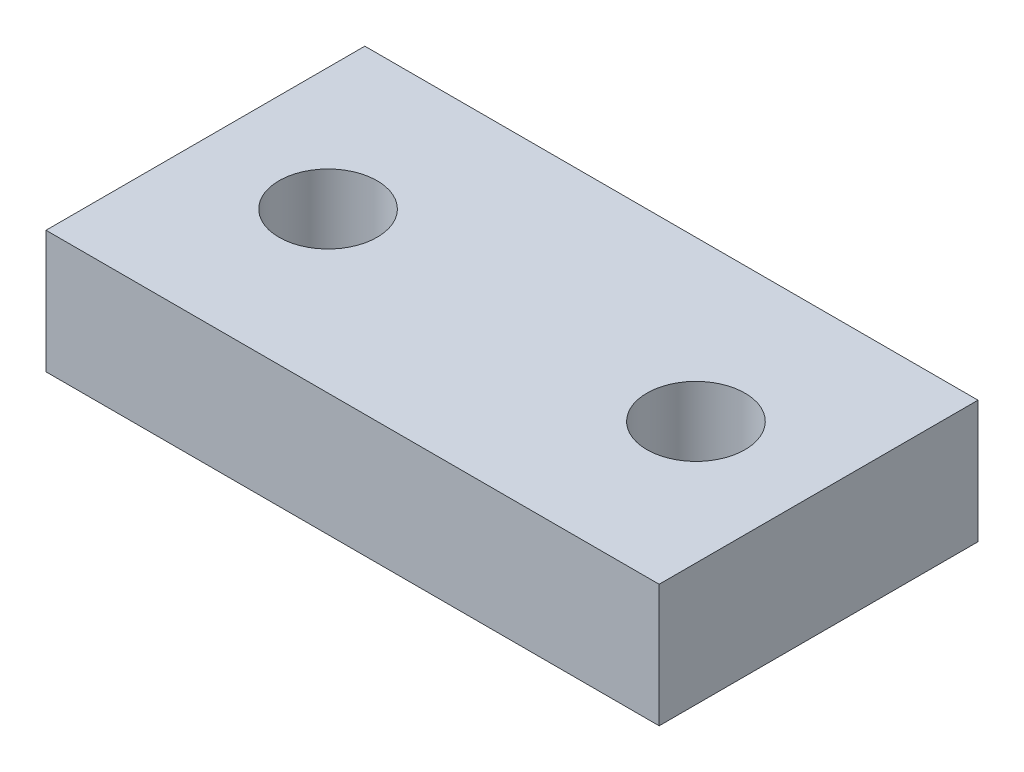
from build123d import *

# Parameters (mm, degrees)
SKETCH1_W           = 25
SKETCH1_H           = 13
SKETCH1_R           = 2
BOSS_EXTRUDE1_DEPTH = 5


with BuildPart() as part:
    # Sketch1 → Boss-Extrude1 (new body)
    with BuildSketch(Plane(origin=(0, 0, 0), x_dir=(1, 0, 0), z_dir=(0, 1, 0))):
        Rectangle(SKETCH1_W, SKETCH1_H)
        with Locations((-7.5, 0)):
            Circle(SKETCH1_R, mode=Mode.SUBTRACT)
        with Locations((7.5, 0)):
            Circle(SKETCH1_R, mode=Mode.SUBTRACT)
    extrude(amount=BOSS_EXTRUDE1_DEPTH)


solid = part.part
